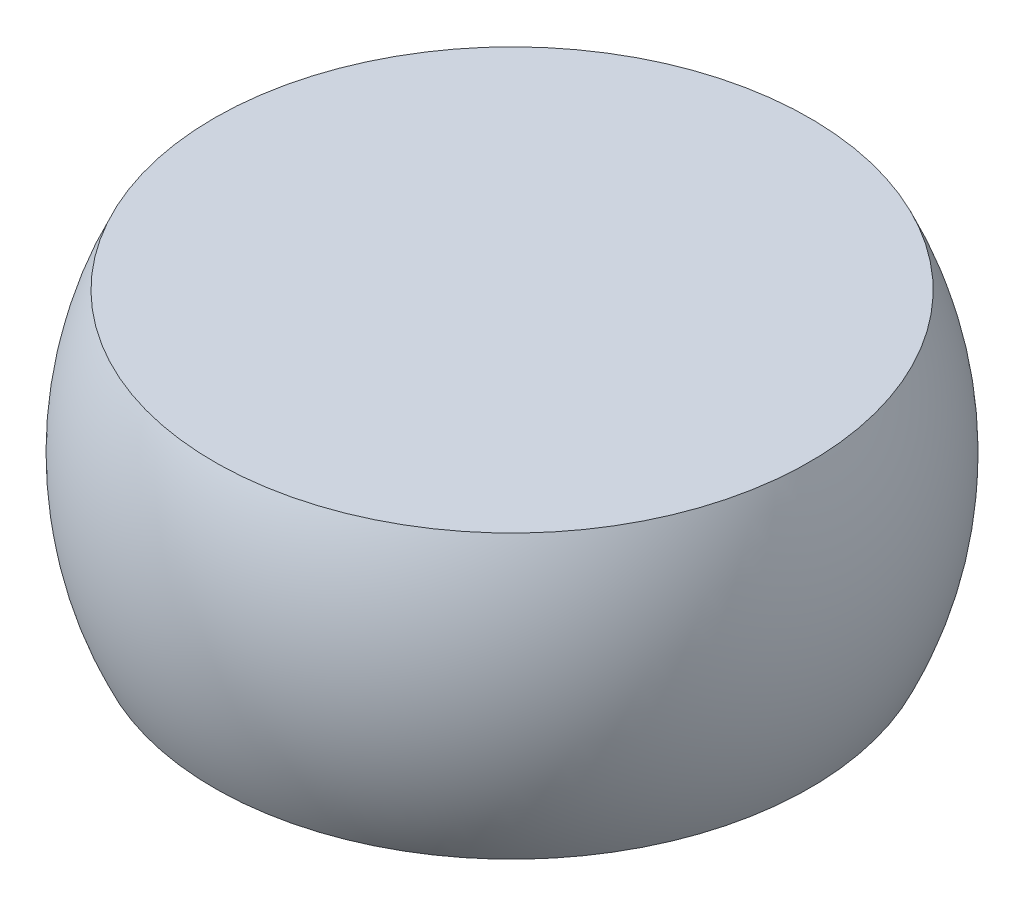
from build123d import *


with BuildPart() as part:
    # Sketch1 → Revolve1 (revolve)
    with BuildSketch(Plane.XY):
        with BuildLine():
            Line((0, 0.15), (0, -0.15))
            Line((0, -0.15), (0.316227766, -0.15))
            ThreePointArc((0.316227766, -0.15), (0.35, 0), (0.316227766, 0.15))
            Line((0.316227766, 0.15), (0, 0.15))
        make_face()
    revolve(axis=Axis((0, 0.15, 0), (0, -1, 0)))


solid = part.part
